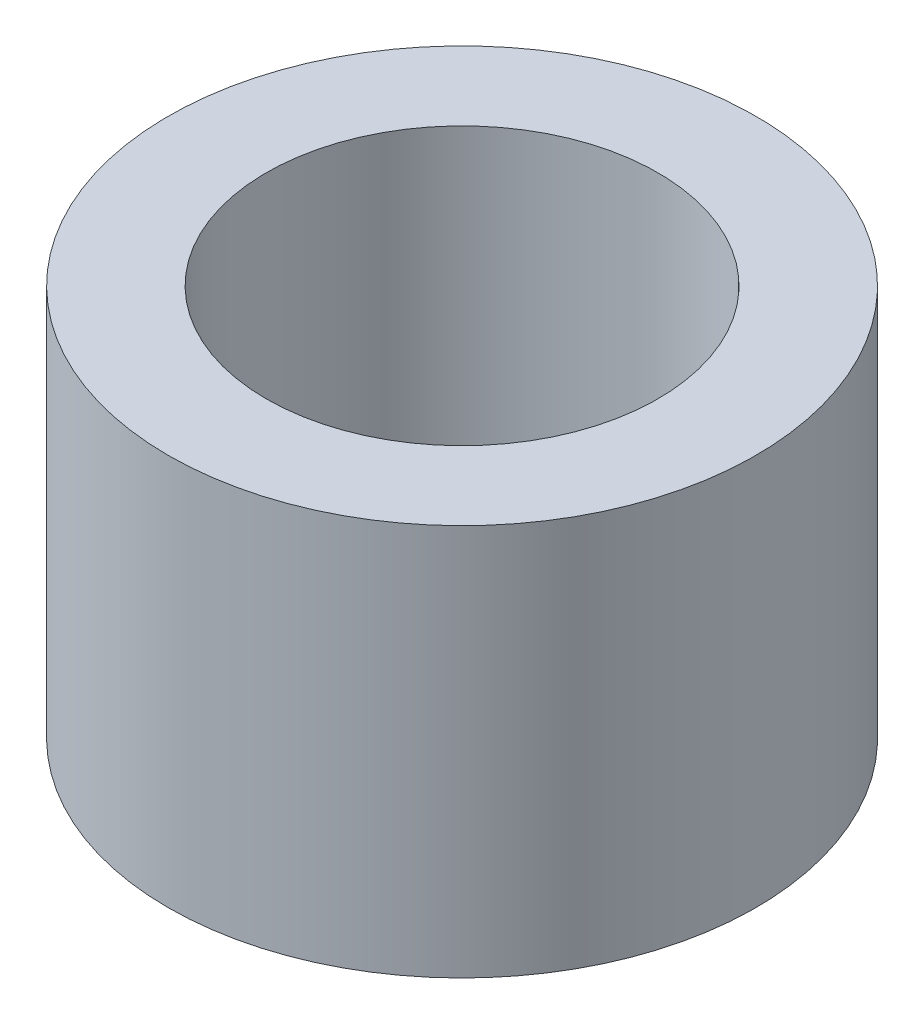
from build123d import *

# Parameters (mm, degrees)
SKETCH1_R           = 9.525
SKETCH1_R_2         = 6.35
BOSS_EXTRUDE1_DEPTH = 12.7


with BuildPart() as part:
    # Sketch1 → Boss-Extrude1 (new body)
    with BuildSketch(Plane(origin=(0, 0, 0), x_dir=(1, 0, 0), z_dir=(0, 1, 0))):
        with Locations((-10.608993193, -4.891262371)):
            Circle(SKETCH1_R)
        with Locations((-10.608993193, -4.891262371)):
            Circle(SKETCH1_R_2, mode=Mode.SUBTRACT)
    extrude(amount=BOSS_EXTRUDE1_DEPTH)


solid = part.part
